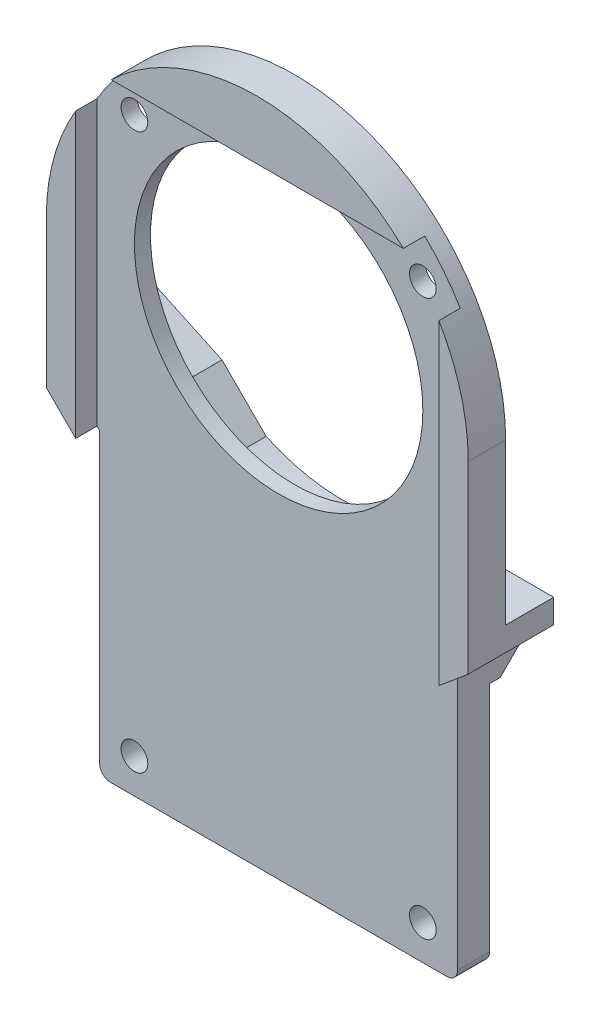
from build123d import *

# Parameters (mm, degrees)
SKETCH_1_R          = 1.25
SKETCH_1_R_2        = 13.5
EXTRUDE_1_DEPTH     = 5
SKETCH_2_R          = 2.75
CUT_EXTRUDE_1_DEPTH = 1
SKETCH_4_W          = 34
SKETCH_4_H          = 59
CUT_EXTRUDE_3_DEPTH = 2
EXTRUDE_2_DEPTH     = 3
CHAMFER_1_SIZE      = 2
CUT_EXTRUDE_4_DEPTH = 1.5
FILLET_3_R          = 1


with BuildPart() as part:
    # 草图1 → 凸台-拉伸1 (new body)
    with BuildSketch(Plane.XY):
        with BuildLine():
            Line((-16.75, -16.75), (-16.75, -44.75))
            Line((-16.75, -44.75), (16.75, -44.75))
            Line((16.75, -44.75), (16.75, -19.75))
            Line((16.75, -19.75), (19.75, -17.232701106))
            Line((19.75, -17.232701106), (19.75, 0))
            ThreePointArc((19.75, 0), (0, 19.75), (-19.75, 0))
            Line((-19.75, 0), (-19.75, -13.75))
            Line((-19.75, -13.75), (-16.75, -16.75))
        make_face()
        with Locations((-13.5, -41.5)):
            Circle(SKETCH_1_R, mode=Mode.SUBTRACT)
        with Locations((13.5, -41.5)):
            Circle(SKETCH_1_R, mode=Mode.SUBTRACT)
        Circle(SKETCH_1_R_2, mode=Mode.SUBTRACT)
        with Locations((-13.5, 10.5)):
            Circle(SKETCH_1_R, mode=Mode.SUBTRACT)
        with Locations((13.5, 10.5)):
            Circle(SKETCH_1_R, mode=Mode.SUBTRACT)
    extrude(amount=EXTRUDE_1_DEPTH)

    # 草图2 → 切除-拉伸1 (cut)
    with BuildSketch(Plane(origin=(0, 0, 0), x_dir=(-1, 0, 0), z_dir=(0, 0, -1))):
        with Locations((-13.5, -41.5)):
            Circle(SKETCH_2_R)
        with Locations((13.5, -41.5)):
            Circle(SKETCH_2_R)
    extrude(amount=-CUT_EXTRUDE_1_DEPTH, mode=Mode.SUBTRACT)

    # 草图4 → 切除-拉伸3 (cut)
    with BuildSketch(Plane.XY.offset(5)):
        with Locations((0, -15.25)):
            Rectangle(SKETCH_4_W, SKETCH_4_H)
    extrude(amount=-CUT_EXTRUDE_3_DEPTH, mode=Mode.SUBTRACT)

    # 草图5 → 凸台-拉伸2 (add)
    with BuildSketch(Plane(origin=(0, 0, 0), x_dir=(-1, 0, 0), z_dir=(0, 0, -1))):
        with BuildLine():
            Line((-16.75, -22), (13.75, -22))
            Line((13.75, -22), (16.75, -19))
            Line((16.75, -19), (16.75, -16.75))
            Line((16.75, -16.75), (19.75, -13.75))
            Line((19.75, -13.75), (19.75, -7.341092536))
            Line((19.75, -7.341092536), (11.300756088, -11.281039678))
            Line((11.300756088, -11.281039678), (7.165897883, -15.415897883))
            ThreePointArc((7.165897883, -15.415897883), (-0.466019686, -16.993611319), (-8, -15))
            Line((-8, -15), (-19.75, -15))
            Line((-19.75, -15), (-19.75, -17.232701106))
            Line((-19.75, -17.232701106), (-16.75, -19.75))
            Line((-16.75, -19.75), (-16.75, -22))
        make_face()
    extrude(amount=EXTRUDE_2_DEPTH)

    # 倒角1
    chamfer_1_edges = [part.edges().sort_by_distance(p)[0] for p in [
        (1.5, -22, -3),
        (-15.25, -20.5, -3),
    ]]
    chamfer(chamfer_1_edges, length=CHAMFER_1_SIZE)

    # 草图8 → 切除-拉伸4 (cut)
    with BuildSketch(Plane(origin=(0, 0, 0), x_dir=(-1, 0, 0), z_dir=(0, 0, -1))):
        with BuildLine():
            Line((-19.75, -15), (-8, -15))
            ThreePointArc((-8, -15), (-0.466019686, -16.993611319), (7.165897883, -15.415897883))
            Line((7.165897883, -15.415897883), (11.300756088, -11.281039678))
            Line((11.300756088, -11.281039678), (19.75, -7.341092536))
            Line((19.75, -7.341092536), (19.75, 0))
            ThreePointArc((19.75, 0), (0, 19.75), (-19.75, 0))
            Line((-19.75, 0), (-19.75, -15))
        make_face()
    extrude(amount=-CUT_EXTRUDE_4_DEPTH, mode=Mode.SUBTRACT)

    # 圆角3
    fillet_3_edges = [part.edges().sort_by_distance(p)[0] for p in [
        (16.75, -44.75, 1.5),
        (-16.75, -44.75, 1.5),
    ]]
    fillet(fillet_3_edges, radius=FILLET_3_R)


solid = part.part
